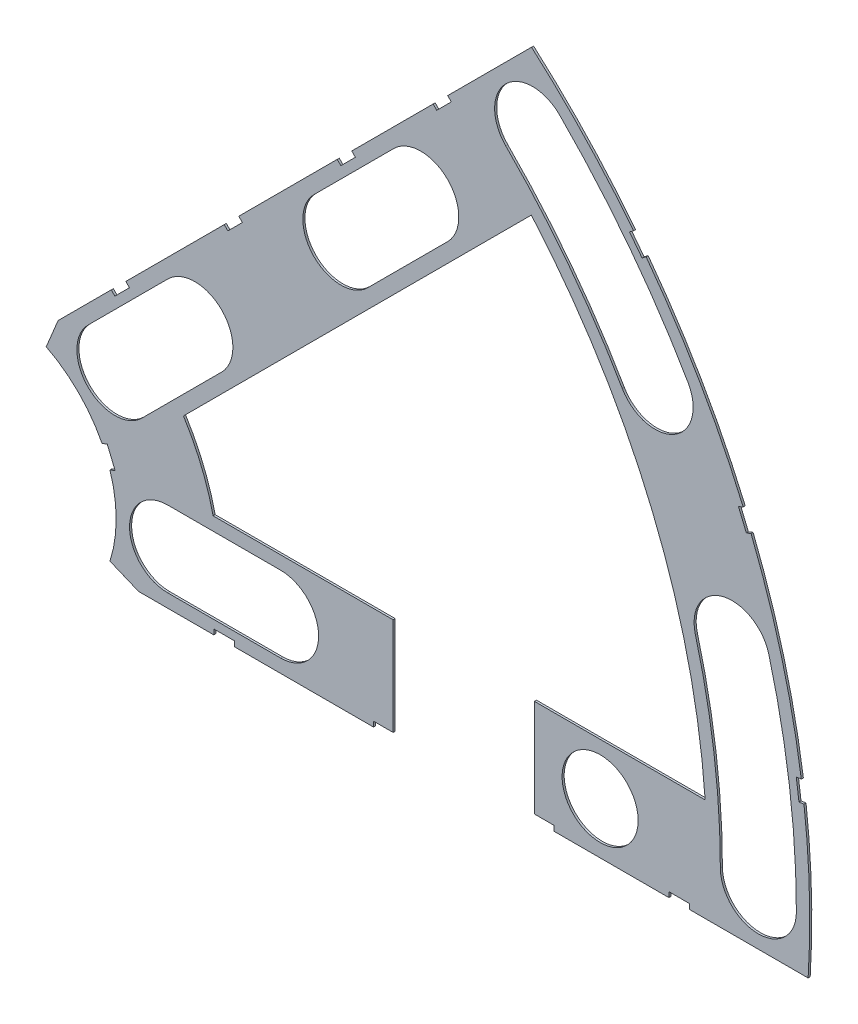
from build123d import *

# Parameters (mm, degrees)
BOSS_EXTRUDE1_DEPTH = 0.254
SKETCH2_R           = 4.699
CUT_EXTRUDE1_DEPTH  = 1.254
SKETCH3_W           = 2.54
SKETCH3_H           = 0.635
CUT_EXTRUDE2_DEPTH  = 1.254
CUT_EXTRUDE4_DEPTH  = 1.254
SKETCH5_W           = 17.4625
SKETCH5_H           = 15.24
CUT_EXTRUDE5_DEPTH  = 1.254


with BuildPart() as part:
    # Sketch1 → Boss-Extrude1 (new body)
    with BuildSketch(Plane.XY):
        with BuildLine():
            Line((67.21146711, 76.191723231), (8.696654013, 17.676910134))
            Line((8.696654013, 17.676910134), (7.228954972, 14.133571205))
            ThreePointArc((7.228954972, 14.133571205), (14.666587579, 6.075099489), (15.105587123, -4.88230096))
            Line((15.105587123, -4.88230096), (18.648926052, -6.35))
            Line((18.648926052, -6.35), (101.401368334, -6.35))
            ThreePointArc((101.401368334, -6.35), (93.866160503, 38.880636728), (67.21146711, 76.191723231))
        make_face()
        with BuildLine():
            Line((88.672924278, 6.35), (27.86051193, 6.35))
            ThreePointArc((27.86051193, 6.35), (26.399857642, 10.93517908), (24.190484974, 15.210228852))
            Line((24.190484974, 15.210228852), (67.191354125, 58.211098004))
            ThreePointArc((67.191354125, 58.211098004), (82.13289044, 34.020557137), (88.672924278, 6.35))
        make_face(mode=Mode.SUBTRACT)
    extrude(amount=BOSS_EXTRUDE1_DEPTH)

    # Sketch2 → Cut-Extrude1 (cut, through all)
    with BuildSketch(Plane.XY.offset(0.254)):
        with Locations((22.225, 0)):
            Circle(SKETCH2_R)
        with Locations((36.195, 0)):
            Circle(SKETCH2_R)
        with Locations((61.722, 0)):
            Circle(SKETCH2_R)
        with Locations((75.692, 0)):
            Circle(SKETCH2_R)
        with Locations((95.25, 0)):
            Circle(SKETCH2_R)
        with Locations((15.715448212, 15.715448212)):
            Circle(SKETCH2_R)
        with Locations((25.593729945, 25.593729945)):
            Circle(SKETCH2_R)
        with Locations((43.644044748, 43.644044748)):
            Circle(SKETCH2_R)
        with Locations((53.522326482, 53.522326482)):
            Circle(SKETCH2_R)
        with Locations((92.004434954, 24.652514046)):
            Circle(SKETCH2_R)
        with Locations((82.48891971, 47.625)):
            Circle(SKETCH2_R)
        with Locations((67.351920908, 67.351920908)):
            Circle(SKETCH2_R)
    extrude(amount=-CUT_EXTRUDE1_DEPTH, mode=Mode.SUBTRACT)

    # Sketch3 → Cut-Extrude2 (cut, through all)
    with BuildSketch(Plane.XY.offset(0.254)):
        Polygon((15.266435406, 24.246691527), (17.06248663, 26.042742751), (17.511499436, 25.593729945), (15.715448212, 23.797678721), align=None)
        Polygon((44.991083167, 53.971339288), (43.195031942, 52.175288063), (43.644044748, 51.726275257), (45.440095973, 53.522326482), align=None)
        with Locations((29.21, -6.0325)):
            Rectangle(SKETCH3_W, SKETCH3_H)
        with Locations((68.707, -6.0325)):
            Rectangle(SKETCH3_W, SKETCH3_H)
        Polygon((29.230733674, 38.210989795), (31.026784898, 40.007041019), (31.475797704, 39.558028213), (29.67974648, 37.761976989), align=None)
        Polygon((56.845021246, 65.825277367), (55.048970022, 64.029226143), (55.497982828, 63.580213337), (57.294034052, 65.376264561), align=None)
        with Locations((48.9585, -6.0325)):
            Rectangle(SKETCH3_W, SKETCH3_H)
        with Locations((85.471, -6.0325)):
            Rectangle(SKETCH3_W, SKETCH3_H)
        Polygon((99.935462164, 14.437711971), (100.266998693, 11.919442024), (101.526133667, 12.085210288), (101.194597138, 14.603480236), align=None)
        Polygon((93.765504959, 37.464305742), (94.938831965, 37.950313702), (93.966816047, 40.296967714), (92.793489041, 39.810959755), align=None)
        Polygon((79.327792988, 62.471156422), (80.874047017, 60.456038938), (81.88160576, 61.229165953), (80.33535173, 63.244283437), align=None)
        Polygon((13.593916116, 7.005422516), (14.565932035, 4.658768503), (15.739259041, 5.144776462), (14.767243123, 7.491430475), align=None)
    extrude(amount=-CUT_EXTRUDE2_DEPTH, mode=Mode.SUBTRACT)

    # Sketch6 → Cut-Extrude4 (cut, through all)
    with BuildSketch(Plane.XY.offset(0.254)):
        with BuildLine():
            Line((12.392753447, 19.038142977), (22.27103518, 28.91642471))
            ThreePointArc((22.27103518, 28.91642471), (28.91642471, 28.91642471), (28.91642471, 22.27103518))
            Line((28.91642471, 22.27103518), (19.038142977, 12.392753447))
            ThreePointArc((19.038142977, 12.392753447), (12.392753447, 12.392753447), (12.392753447, 19.038142977))
        make_face()
        with BuildLine():
            Line((40.321349984, 46.966739513), (50.199631717, 56.845021246))
            ThreePointArc((50.199631717, 56.845021246), (56.845021246, 56.845021246), (56.845021246, 50.199631717))
            Line((56.845021246, 50.199631717), (46.966739513, 40.321349984))
            ThreePointArc((46.966739513, 40.321349984), (40.321349984, 40.321349984), (40.321349984, 46.966739513))
        make_face()
        with BuildLine():
            Line((22.225, 4.699), (36.195, 4.699))
            ThreePointArc((36.195, 4.699), (40.894, 0), (36.195, -4.699))
            Line((36.195, -4.699), (22.225, -4.699))
            ThreePointArc((22.225, -4.699), (17.526, 0), (22.225, 4.699))
        make_face()
        with BuildLine():
            ThreePointArc((99.949, 0), (99.093922449, 13.045962386), (96.543320412, 25.868704739))
            ThreePointArc((96.543320412, 25.868704739), (90.788244261, 29.191399504), (87.465549496, 23.436323353))
            ThreePointArc((87.465549496, 23.436323353), (89.776323642, 11.819277232), (90.551, 0))
            ThreePointArc((90.551, 0), (95.25, -4.699), (99.949, 0))
        make_face()
        with BuildLine():
            ThreePointArc((86.558373083, 49.9745), (79.294873009, 60.845096068), (70.674615673, 70.674615673))
            ThreePointArc((70.674615673, 70.674615673), (64.029226143, 70.674615673), (64.029226143, 64.029226143))
            ThreePointArc((64.029226143, 64.029226143), (71.838938317, 55.123956158), (78.419466338, 45.2755))
            ThreePointArc((78.419466338, 45.2755), (84.83841971, 43.555546628), (86.558373083, 49.9745))
        make_face()
    extrude(amount=-CUT_EXTRUDE4_DEPTH, mode=Mode.SUBTRACT)

    # Sketch5 → Cut-Extrude5 (cut, through all)
    with BuildSketch(Plane.XY.offset(0.254)):
        with Locations((58.83275, 0)):
            Rectangle(SKETCH5_W, SKETCH5_H)
    extrude(amount=-CUT_EXTRUDE5_DEPTH, mode=Mode.SUBTRACT)


solid = part.part
